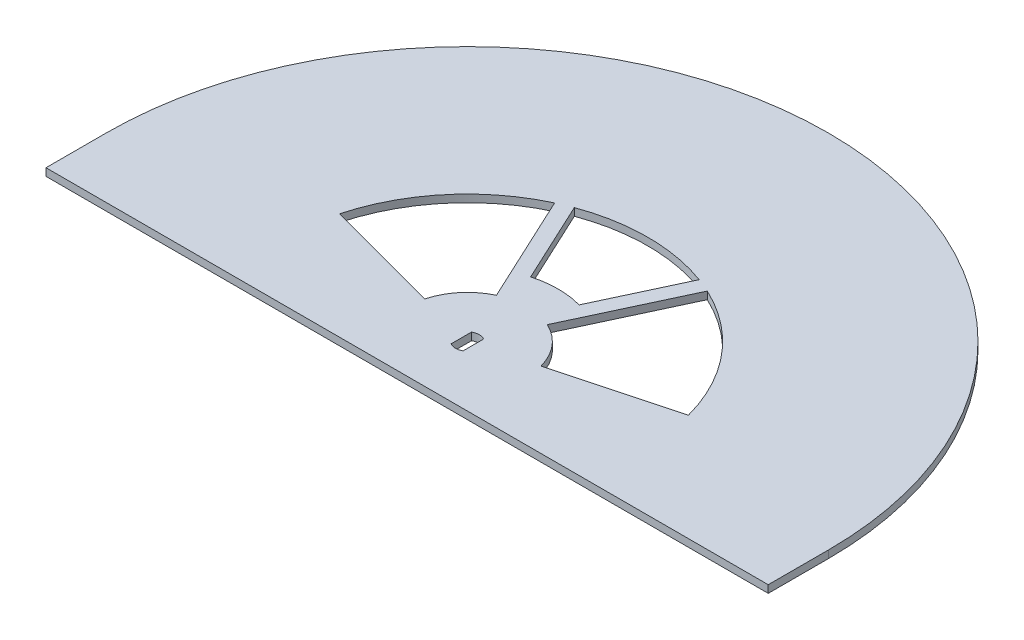
from build123d import *

# Parameters (mm, degrees)
BOSS_EXTRUDE1_DEPTH = 1.5875
SKETCH3_W           = 152.4
SKETCH3_H           = 12.7
BOSS_EXTRUDE3_DEPTH = 1.5875
CUT_EXTRUDE1_DEPTH  = 2.5875


with BuildPart() as part:
    # Sketch1 → Boss-Extrude1 (new body)
    with BuildSketch(Plane(origin=(0, 0, 0), x_dir=(1, 0, 0), z_dir=(0, 1, 0))):
        with BuildLine():
            Line((-76.2, 0), (76.2, 0))
            ThreePointArc((76.2, 0), (0, 76.2), (-76.2, 0))
        make_face()
        with BuildLine():
            Line((-12.267257994, 3.287001873), (-36.801773982, 9.861005618))
            ThreePointArc((-36.801773982, 9.861005618), (-29.186293283, 24.490207929), (-16.101755772, 34.530326686))
            Line((-16.101755772, 34.530326686), (-5.367251924, 11.510108895))
            ThreePointArc((-5.367251924, 11.510108895), (-9.728764428, 8.163402643), (-12.267257994, 3.287001873))
        make_face(mode=Mode.SUBTRACT)
        with BuildLine():
            Line((36.801773982, 9.861005619), (12.267257994, 3.287001873))
            ThreePointArc((12.267257994, 3.287001873), (9.728764427, 8.163402643), (5.367251924, 11.510108895))
            Line((5.367251924, 11.510108895), (16.101755772, 34.530326686))
            ThreePointArc((16.101755772, 34.530326686), (29.186293283, 24.490207929), (36.801773982, 9.861005619))
        make_face(mode=Mode.SUBTRACT)
        with BuildLine():
            Line((-13.168222272, 35.752033819), (-5.117344386, 18.486870476))
            ThreePointArc((-5.117344386, 18.486870476), (0, 19.182064372), (5.117344386, 18.486870476))
            Line((5.117344386, 18.486870476), (13.168222272, 35.752033819))
            ThreePointArc((13.168222272, 35.752033819), (0, 38.1), (-13.168222272, 35.752033819))
        make_face(mode=Mode.SUBTRACT)
    extrude(amount=BOSS_EXTRUDE1_DEPTH)

    # Sketch3 → Boss-Extrude3 (add)
    with BuildSketch(Plane(origin=(0, 1.5875, 0), x_dir=(1, 0, 0), z_dir=(0, 1, 0))):
        with Locations((0, -6.35)):
            Rectangle(SKETCH3_W, SKETCH3_H)
    extrude(amount=-BOSS_EXTRUDE3_DEPTH)

    # Sketch4 → Cut-Extrude1 (cut, through all)
    with BuildSketch(Plane(origin=(0, 1.5875, 0), x_dir=(1, 0, 0), z_dir=(0, 1, 0))):
        with BuildLine():
            Line((-1.275735082, 2.15), (-1.275735082, -2.15))
            ThreePointArc((-1.275735082, -2.15), (0, -2.5), (1.275735082, -2.15))
            Line((1.275735082, -2.15), (1.275735082, 2.15))
            ThreePointArc((1.275735082, 2.15), (0, 2.5), (-1.275735082, 2.15))
        make_face()
    extrude(amount=-CUT_EXTRUDE1_DEPTH, mode=Mode.SUBTRACT)


solid = part.part
